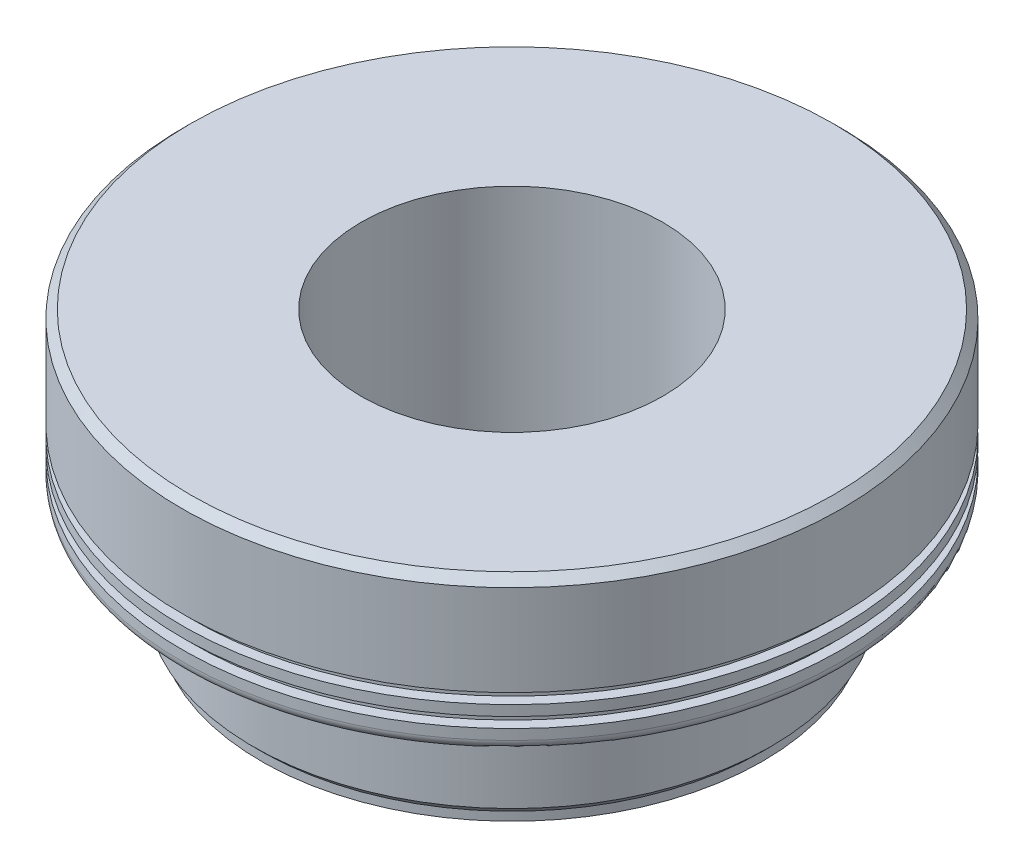
from build123d import *


with BuildPart() as part:
    # Sketch3 → Revolve1 (revolve)
    with BuildSketch(Plane.XY):
        with BuildLine():
            Line((-2, 1.765), (-2, -1.765))
            Line((-2, -1.765), (-3.3229, -1.765))
            Line((-3.3229, -1.765), (-3.3229, -1.65025))
            Line((-3.3229, -1.65025), (-3.43, -1.54315))
            Line((-3.43, -1.54315), (-3.43, -0.628975))
            Line((-3.43, -0.628975), (-3.3229, -0.521875))
            Line((-3.3229, -0.521875), (-3.307578125, -0.521875))
            ThreePointArc((-3.307578125, -0.521875), (-3.231508903, -0.490366097), (-3.2, -0.414296875))
            Line((-3.2, -0.414296875), (-3.2, -0.342578125))
            ThreePointArc((-3.2, -0.342578125), (-3.231508903, -0.266508903), (-3.307578125, -0.235))
            Line((-3.307578125, -0.235), (-4.2325, -0.235))
            ThreePointArc((-4.2325, -0.235), (-4.329727182, -0.194727182), (-4.37, -0.0975))
            Line((-4.37, -0.0975), (-4.37, 0.04))
            Line((-4.37, 0.04), (-4.2325, 0.04))
            Line((-4.2325, 0.04), (-4.2325, 0.1775))
            Line((-4.2325, 0.1775), (-4.37, 0.1775))
            Line((-4.37, 0.1775), (-4.37, 0.315))
            Line((-4.37, 0.315), (-4.2325, 0.315))
            Line((-4.2325, 0.315), (-4.2325, 0.4525))
            Line((-4.2325, 0.4525), (-4.37, 0.4525))
            Line((-4.37, 0.4525), (-4.37, 1.6579))
            Line((-4.37, 1.6579), (-4.2629, 1.765))
            Line((-4.2629, 1.765), (-2, 1.765))
        make_face()
    revolve(axis=Axis((0, -1.765, 0), (0, 1, 0)))


solid = part.part
